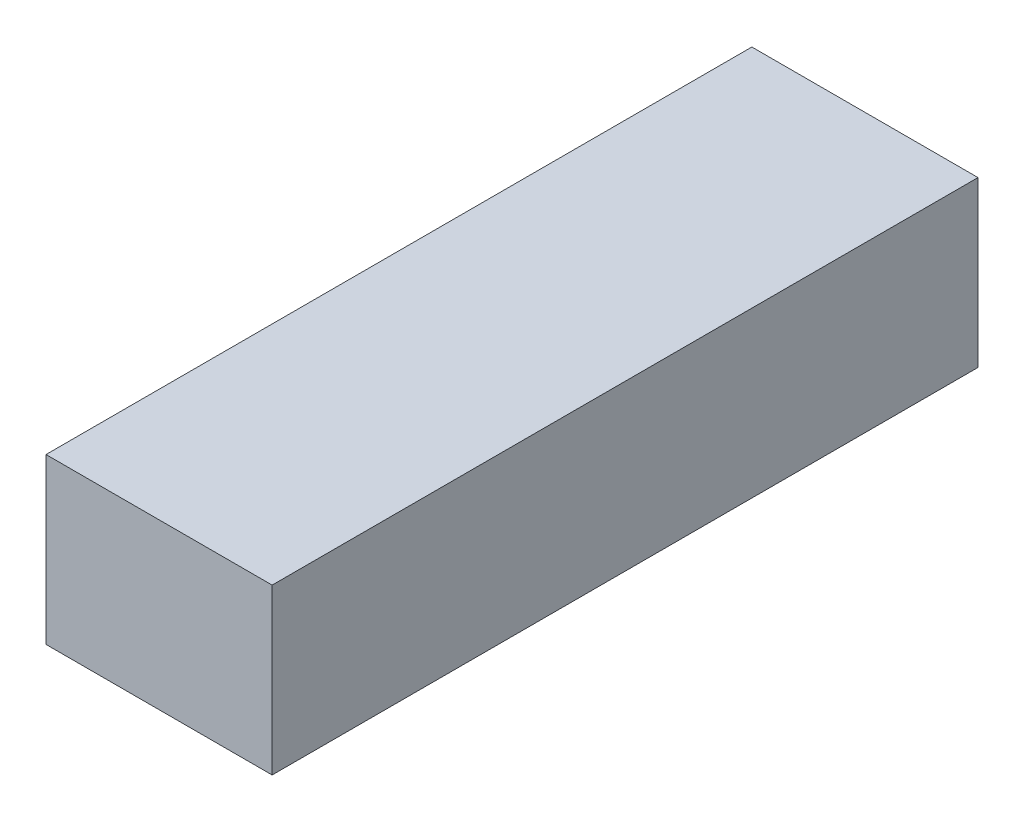
from build123d import *

# Parameters (mm, degrees)
SKETCH1_W           = 33
SKETCH1_H           = 103
BOSS_EXTRUDE1_DEPTH = 24


with BuildPart() as part:
    # Sketch1 → Boss-Extrude1 (new body)
    with BuildSketch(Plane(origin=(0, 0, 0), x_dir=(1, 0, 0), z_dir=(0, 1, 0))):
        Rectangle(SKETCH1_W, SKETCH1_H)
    extrude(amount=BOSS_EXTRUDE1_DEPTH)


solid = part.part
